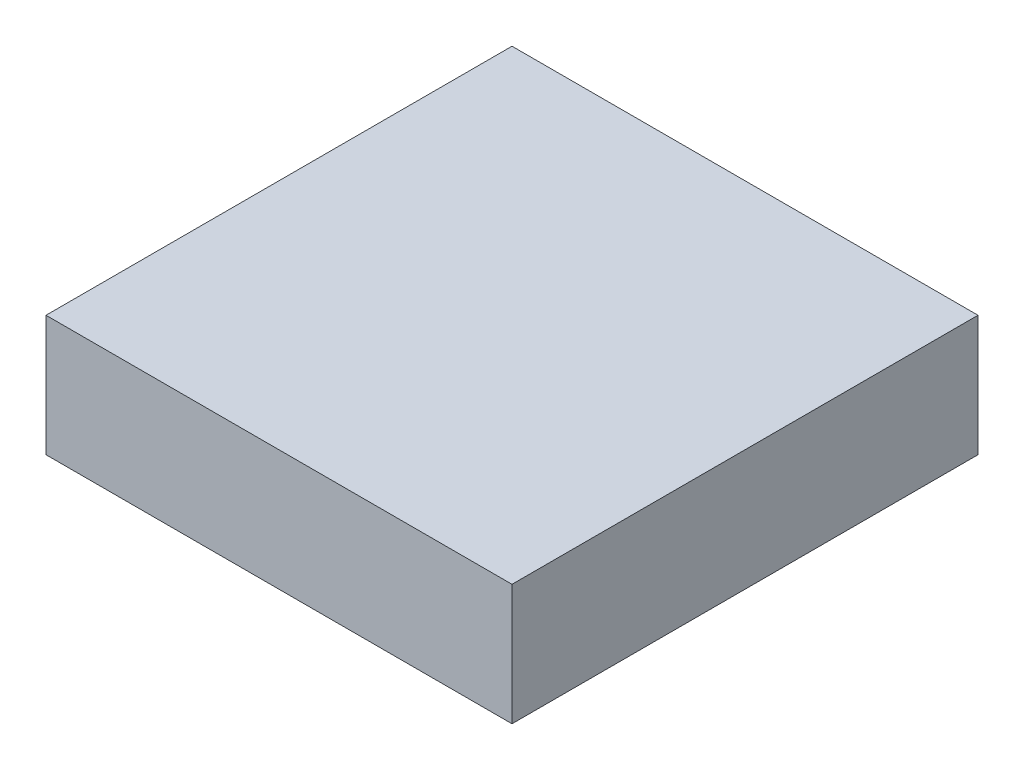
from build123d import *

# Parameters (mm, degrees)
SKETCH1_W           = 27
SKETCH1_H           = 27
BOSS_EXTRUDE1_DEPTH = 7


with BuildPart() as part:
    # Sketch1 → Boss-Extrude1 (new body)
    with BuildSketch(Plane(origin=(0, 0, 0), x_dir=(1, 0, 0), z_dir=(0, 1, 0))):
        with Locations((13.5, 13.5)):
            Rectangle(SKETCH1_W, SKETCH1_H)
    extrude(amount=BOSS_EXTRUDE1_DEPTH)


solid = part.part
